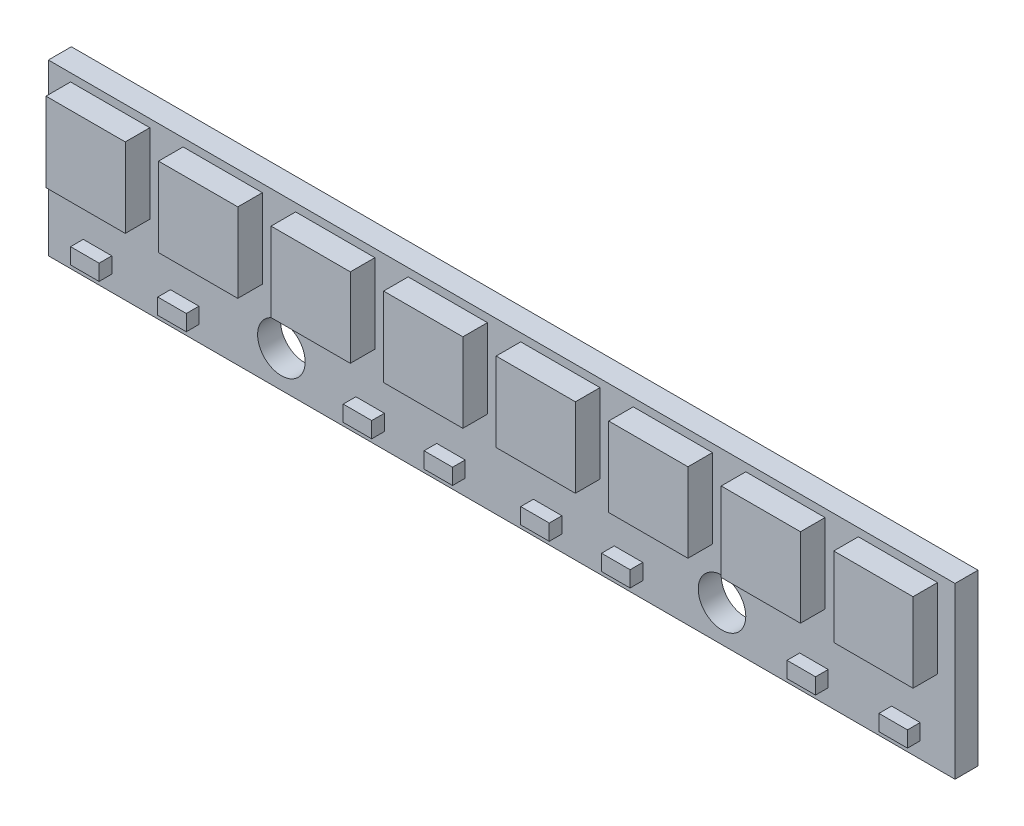
from build123d import *

# Parameters (mm, degrees)
CROQUIS1_W              = 57.2
CROQUIS1_H              = 10.7
SALIENTE_EXTRUIR1_DEPTH = 1.45
CROQUIS2_W              = 5
CROQUIS2_H              = 5
SALIENTE_EXTRUIR2_DEPTH = 1.55
MATRIZL1_COUNT          = 8
MATRIZL1_PITCH          = 7.1
CORTAR_EXTRUIR1_REACH   = 3.45
CROQUIS3_R              = 1.5
CROQUIS4_W              = 1.8
CROQUIS4_H              = 1
SALIENTE_EXTRUIR3_DEPTH = 0.8


with BuildPart() as part:
    # Croquis1 → Saliente-Extruir1 (new body)
    with BuildSketch(Plane.XY):
        with Locations((28.6, 5.35)):
            Rectangle(CROQUIS1_W, CROQUIS1_H)
    extrude(amount=SALIENTE_EXTRUIR1_DEPTH)

    # Croquis2 → Saliente-Extruir2 (add)
    with BuildSketch(Plane.XY.offset(1.45)):
        with Locations((3.9, 7.7)):
            Rectangle(CROQUIS2_W, CROQUIS2_H)
    saliente_extruir2 = extrude(amount=SALIENTE_EXTRUIR2_DEPTH)

    # MatrizL1: Saliente-Extruir2 ×8
    with Locations(*[(i * MATRIZL1_PITCH, 0, 0) for i in range(1, MATRIZL1_COUNT)]):
        add(saliente_extruir2)

    # Croquis3 → Cortar-Extruir1 (cut, up to next)
    with BuildSketch(Plane.XY.offset(1.45), mode=Mode.PRIVATE) as cortar_extruir1_sk1:
        with Locations((14.7, 2.3)):
            Circle(CROQUIS3_R)
    cortar_extruir1_tool1 = extrude(cortar_extruir1_sk1.sketch, amount=-CORTAR_EXTRUIR1_REACH, mode=Mode.PRIVATE) & part.part
    add(cortar_extruir1_tool1.solids().sort_by_distance((14.7, 2.3, 1.45))[0], mode=Mode.SUBTRACT)
    # Croquis3 → Cortar-Extruir1 (cut, up to next)
    with BuildSketch(Plane.XY.offset(1.45), mode=Mode.PRIVATE) as cortar_extruir1_sk2:
        with Locations((42.5, 2.3)):
            Circle(CROQUIS3_R)
    cortar_extruir1_tool2 = extrude(cortar_extruir1_sk2.sketch, amount=-CORTAR_EXTRUIR1_REACH, mode=Mode.PRIVATE) & part.part
    add(cortar_extruir1_tool2.solids().sort_by_distance((42.5, 2.3, 1.45))[0], mode=Mode.SUBTRACT)

    # Croquis4 → Saliente-Extruir3 (add)
    with BuildSketch(Plane.XY.offset(1.45)):
        with Locations((3.1, 1.5)):
            Rectangle(CROQUIS4_W, CROQUIS4_H)
        with Locations((8.6, 1.5)):
            Rectangle(CROQUIS4_W, CROQUIS4_H)
        with Locations((20.3, 1.5)):
            Rectangle(CROQUIS4_W, CROQUIS4_H)
        with Locations((25.4, 1.5)):
            Rectangle(CROQUIS4_W, CROQUIS4_H)
        with Locations((31.5, 1.5)):
            Rectangle(CROQUIS4_W, CROQUIS4_H)
        with Locations((36.6, 1.5)):
            Rectangle(CROQUIS4_W, CROQUIS4_H)
        with Locations((48.3, 1.5)):
            Rectangle(CROQUIS4_W, CROQUIS4_H)
        with Locations((54.1, 1.5)):
            Rectangle(CROQUIS4_W, CROQUIS4_H)
    extrude(amount=SALIENTE_EXTRUIR3_DEPTH)


solid = part.part
